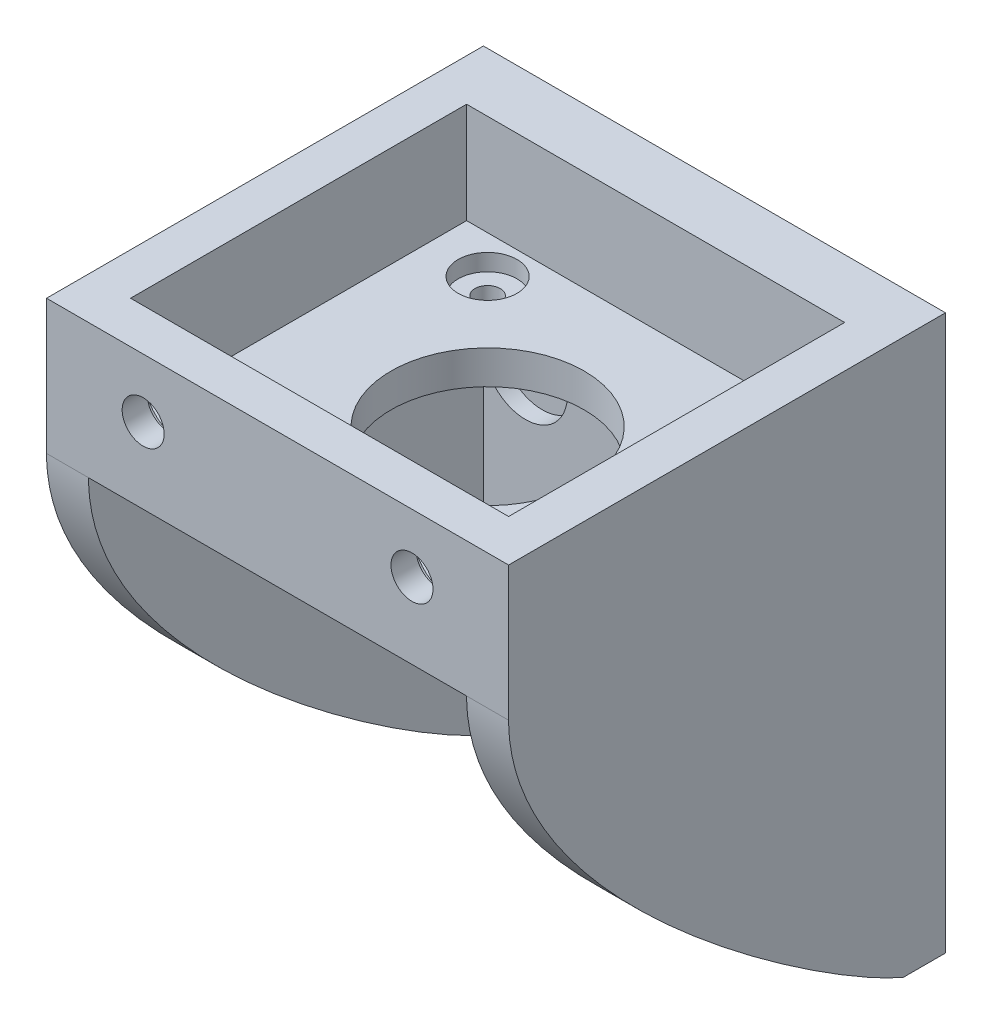
from build123d import *

# Parameters (mm, degrees)
SKETCH1_W           = 55
SKETCH1_H           = 50
SKETCH1_R           = 2.5
BOSS_EXTRUDE1_DEPTH = 5
SKETCH2_R           = 5
CUT_EXTRUDE1_DEPTH  = 2
SKETCH3_W           = 55
SKETCH3_H           = 52
BOSS_EXTRUDE2_DEPTH = 16
SKETCH4_R           = 11.5
SKETCH4_R_2         = 1.5
CUT_EXTRUDE2_DEPTH  = 17
BOSS_EXTRUDE3_DEPTH = 5
SKETCH6_W           = 45
SKETCH6_H           = 40
CUT_EXTRUDE3_DEPTH  = 12
SKETCH7_R           = 3.5
CUT_EXTRUDE4_DEPTH  = 2
SKETCH8_R           = 2.5
CUT_EXTRUDE5_DEPTH  = 5
SKETCH10_R          = 5
CUT_EXTRUDE6_DEPTH  = 2


with BuildPart() as part:
    # Sketch1 → Boss-Extrude1 (new body)
    with BuildSketch(Plane.XY):
        Rectangle(SKETCH1_W, SKETCH1_H)
        with Locations((-17.5, -15)):
            Circle(SKETCH1_R, mode=Mode.SUBTRACT)
        with Locations((17.5, -15)):
            Circle(SKETCH1_R, mode=Mode.SUBTRACT)
        with Locations((-17.5, 15)):
            Circle(SKETCH1_R, mode=Mode.SUBTRACT)
        with Locations((17.5, 15)):
            Circle(SKETCH1_R, mode=Mode.SUBTRACT)
    extrude(amount=BOSS_EXTRUDE1_DEPTH)

    # Sketch2 → Cut-Extrude1 (cut)
    with BuildSketch(Plane.XY.offset(5)):
        with Locations((-17.5, -15)):
            Circle(SKETCH2_R)
        with Locations((17.5, -15)):
            Circle(SKETCH2_R)
        with Locations((-17.5, 15)):
            Circle(SKETCH2_R)
        with Locations((17.5, 15)):
            Circle(SKETCH2_R)
    extrude(amount=-CUT_EXTRUDE1_DEPTH, mode=Mode.SUBTRACT)

    # Sketch3 → Boss-Extrude2 (add)
    with BuildSketch(Plane(origin=(0, 25, 0), x_dir=(1, 0, 0), z_dir=(0, 1, 0))):
        with Locations((0, -26)):
            Rectangle(SKETCH3_W, SKETCH3_H)
    extrude(amount=BOSS_EXTRUDE2_DEPTH)

    # Sketch4 → Cut-Extrude2 (cut, through all)
    with BuildSketch(Plane(origin=(0, 25, 0), x_dir=(-1, 0, 0), z_dir=(0, -1, 0))):
        with Locations((0, -27)):
            Circle(SKETCH4_R)
        with Locations((15.5, -42.5)):
            Circle(SKETCH4_R_2)
        with Locations((-15.5, -42.5)):
            Circle(SKETCH4_R_2)
        with Locations((-15.5, -11.5)):
            Circle(SKETCH4_R_2)
        with Locations((15.5, -11.5)):
            Circle(SKETCH4_R_2)
    extrude(amount=-CUT_EXTRUDE2_DEPTH, mode=Mode.SUBTRACT)

    # Sketch5 → Boss-Extrude3 (add)
    with BuildSketch(Plane.ZY.offset(27.5)):
        with BuildLine():
            Line((5, -25), (5, 25))
            Line((5, 25), (52, 25))
            add(Edge.make_bspline(
                [(52, 25), (52, 4.232970162), (15.26663468, -20.719918254), (5, -25)],
                knots=[0, 0, 0, 0, 0.911487557, 0.911487557, 0.911487557, 0.911487557], degree=3))
        make_face()
    boss_extrude3 = extrude(amount=-BOSS_EXTRUDE3_DEPTH)

    # Mirror1: Boss-Extrude3 across plane
    add(boss_extrude3.mirror(Plane(origin=(0, 0, 0), x_dir=(0, 0, 1), z_dir=(1, 0, 0))))

    # Sketch6 → Cut-Extrude3 (cut)
    with BuildSketch(Plane(origin=(0, 41, 0), x_dir=(1, 0, 0), z_dir=(0, 1, 0))):
        with Locations((0, -27)):
            Rectangle(SKETCH6_W, SKETCH6_H)
    extrude(amount=-CUT_EXTRUDE3_DEPTH, mode=Mode.SUBTRACT)

    # Sketch7 → Cut-Extrude4 (cut)
    with BuildSketch(Plane(origin=(0, 29, 0), x_dir=(1, 0, 0), z_dir=(0, 1, 0))):
        with Locations((-15.5, -11.5)):
            Circle(SKETCH7_R)
        with Locations((15.5, -11.5)):
            Circle(SKETCH7_R)
        with Locations((15.5, -42.5)):
            Circle(SKETCH7_R)
        with Locations((-15.5, -42.5)):
            Circle(SKETCH7_R)
    extrude(amount=-CUT_EXTRUDE4_DEPTH, mode=Mode.SUBTRACT)

    # Sketch8 → Cut-Extrude5 (cut)
    with BuildSketch(Plane.XY.offset(52)):
        with Locations((16, 34)):
            Circle(SKETCH8_R)
        with Locations((-16, 34)):
            Circle(SKETCH8_R)
    extrude(amount=-CUT_EXTRUDE5_DEPTH, mode=Mode.SUBTRACT)

    # Sketch10 → Cut-Extrude6 (cut)
    with BuildSketch(Plane(origin=(0, 0, 47), x_dir=(-1, 0, 0), z_dir=(0, 0, -1))):
        with Locations((-16, 34)):
            Circle(SKETCH10_R)
        with Locations((16, 34)):
            Circle(SKETCH10_R)
    extrude(amount=-CUT_EXTRUDE6_DEPTH, mode=Mode.SUBTRACT)


solid = part.part
